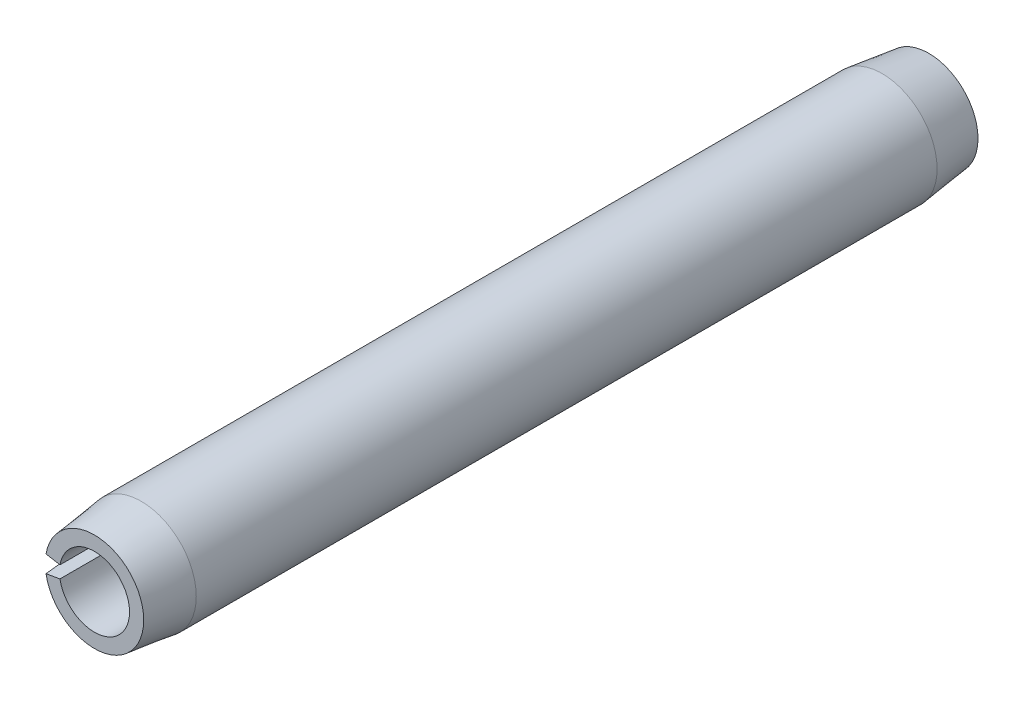
from build123d import *

# Parameters (mm, degrees)
EXTRUDE1_DEPTH = 6.35


with BuildPart() as part:
    # Sketch1 → Extrude1 (new body, symmetric)
    with BuildSketch(Plane.XY):
        with BuildLine():
            Line((-0.825465859, 0.145551903), (-0.525296455, 0.092623938))
            ThreePointArc((-0.525296455, 0.092623938), (0.5334, 0), (-0.525296455, -0.092623938))
            Line((-0.525296455, -0.092623938), (-0.825465859, -0.145551903))
            ThreePointArc((-0.825465859, -0.145551903), (0.8382, 0), (-0.825465859, 0.145551903))
        make_face()
    extrude(amount=EXTRUDE1_DEPTH, both=True)

    # Sketch2 → Cut-Revolve1 (revolve, cut)
    with BuildSketch(Plane(origin=(0, 0, 0), x_dir=(0, 0, -1), z_dir=(1, 0, 0))):
        Polygon((6.35, 0.8382), (6.35, 0.7493), (5.6388, 0.8382), align=None)
        Polygon((-5.6388, 0.8382), (-6.35, 0.8382), (-6.35, 0.7493), align=None)
    revolve(axis=Axis((0, 0, -6.35), (0, 0, 1)), mode=Mode.SUBTRACT)


solid = part.part
